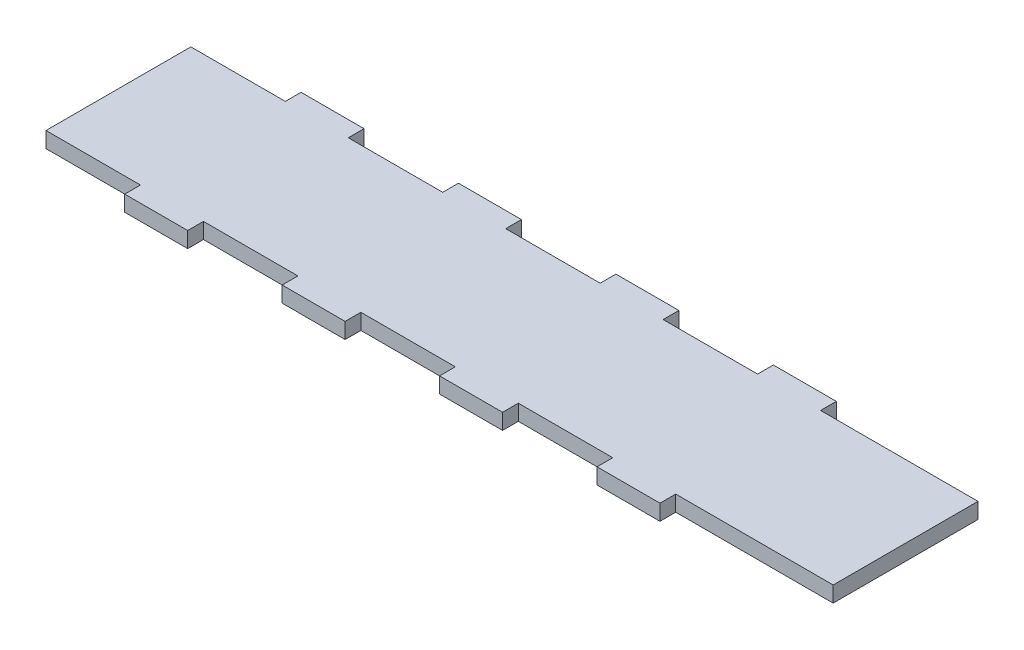
from build123d import *

# Parameters (mm, degrees)
SKETCH1_W          = 158.75
SKETCH1_H          = 35.56
EXTRUDE1_DEPTH     = 3.175
SKETCH3_W          = 19.05
SKETCH3_H          = 3.175
CUT_EXTRUDE1_DEPTH = 4.175


with BuildPart() as part:
    # Sketch1 → Extrude1 (new body)
    with BuildSketch(Plane(origin=(0, 0, 0), x_dir=(1, 0, 0), z_dir=(0, 1, 0))):
        Rectangle(SKETCH1_W, SKETCH1_H)
    extrude(amount=EXTRUDE1_DEPTH)

    # Sketch3 → Cut-Extrude1 (cut, through all)
    with BuildSketch(Plane(origin=(0, 3.175, 0), x_dir=(1, 0, 0), z_dir=(0, 1, 0))):
        Polygon((47.625, -14.605), (66.675, -14.605), (79.375, -14.605), (79.375, -17.78), (66.675, -17.78), (47.625, -17.78), align=None)
        with Locations((-69.85, 16.1925)):
            Rectangle(SKETCH3_W, SKETCH3_H)
        Polygon((66.675, 17.78), (79.375, 17.78), (79.375, 14.605), (66.675, 14.605), (47.625, 14.605), (47.625, 17.78), align=None)
        with Locations((25.4, -16.1925)):
            Rectangle(SKETCH3_W, SKETCH3_H)
        with Locations((-6.35, -16.1925)):
            Rectangle(SKETCH3_W, SKETCH3_H)
        with Locations((-38.1, -16.1925)):
            Rectangle(SKETCH3_W, SKETCH3_H)
        with Locations((-69.85, -16.1925)):
            Rectangle(SKETCH3_W, SKETCH3_H)
        with Locations((-38.1, 16.1925)):
            Rectangle(SKETCH3_W, SKETCH3_H)
        with Locations((-6.35, 16.1925)):
            Rectangle(SKETCH3_W, SKETCH3_H)
        with Locations((25.4, 16.1925)):
            Rectangle(SKETCH3_W, SKETCH3_H)
    extrude(amount=-CUT_EXTRUDE1_DEPTH, mode=Mode.SUBTRACT)


solid = part.part
